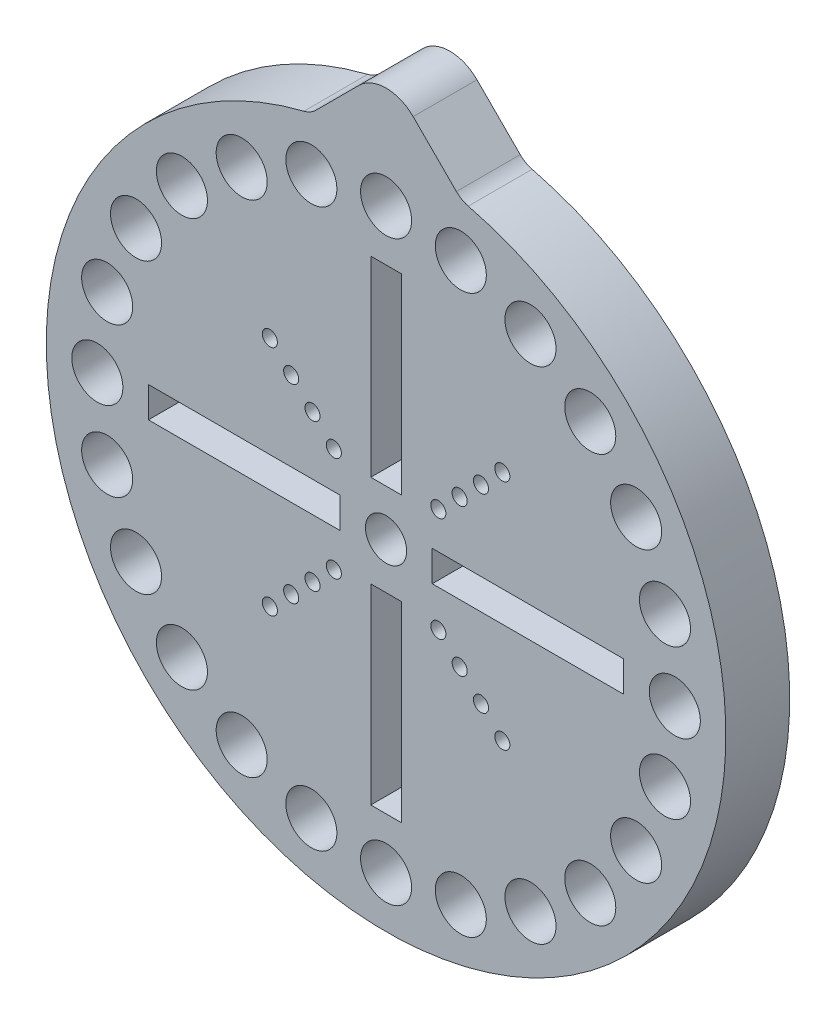
from build123d import *

# Parameters (mm, degrees)
SKETCH1_R           = 33.8
SKETCH1_R_2         = 2.54
SKETCH1_R_3         = 2.05
SKETCH1_R_4         = 0.75
SKETCH1_W           = 3.048
SKETCH1_H           = 19.05
SKETCH1_W_2         = 19.05
SKETCH1_H_2         = 3.048
BOSS_EXTRUDE1_DEPTH = 6.35
BOSS_EXTRUDE2_DEPTH = 6.35
FILLET1_R           = 2.54


with BuildPart() as part:
    # Sketch1 → Boss-Extrude1 (new body)
    with BuildSketch(Plane.XY):
        Circle(SKETCH1_R)
        with Locations((14.36, 24.872249597)):
            Circle(SKETCH1_R_2, mode=Mode.SUBTRACT)
        with Locations((20.308106756, 20.308106756)):
            Circle(SKETCH1_R_2, mode=Mode.SUBTRACT)
        with Locations((24.872249597, 14.36)):
            Circle(SKETCH1_R_2, mode=Mode.SUBTRACT)
        with Locations((27.741389731, 7.433282975)):
            Circle(SKETCH1_R_2, mode=Mode.SUBTRACT)
        with Locations((28.72, 0)):
            Circle(SKETCH1_R_2, mode=Mode.SUBTRACT)
        with Locations((27.741389731, -7.433282975)):
            Circle(SKETCH1_R_2, mode=Mode.SUBTRACT)
        with Locations((24.872249597, -14.36)):
            Circle(SKETCH1_R_2, mode=Mode.SUBTRACT)
        with Locations((20.308106756, -20.308106756)):
            Circle(SKETCH1_R_2, mode=Mode.SUBTRACT)
        with Locations((14.36, -24.872249597)):
            Circle(SKETCH1_R_2, mode=Mode.SUBTRACT)
        with Locations((7.433282975, -27.741389731)):
            Circle(SKETCH1_R_2, mode=Mode.SUBTRACT)
        with Locations((0, -28.72)):
            Circle(SKETCH1_R_2, mode=Mode.SUBTRACT)
        with Locations((-7.433282975, -27.741389731)):
            Circle(SKETCH1_R_2, mode=Mode.SUBTRACT)
        with Locations((-14.36, -24.872249597)):
            Circle(SKETCH1_R_2, mode=Mode.SUBTRACT)
        with Locations((-20.308106756, -20.308106756)):
            Circle(SKETCH1_R_2, mode=Mode.SUBTRACT)
        with Locations((-24.872249597, -14.36)):
            Circle(SKETCH1_R_2, mode=Mode.SUBTRACT)
        with Locations((-27.741389731, -7.433282975)):
            Circle(SKETCH1_R_2, mode=Mode.SUBTRACT)
        with Locations((-28.72, 0)):
            Circle(SKETCH1_R_2, mode=Mode.SUBTRACT)
        with Locations((-27.741389731, 7.433282975)):
            Circle(SKETCH1_R_2, mode=Mode.SUBTRACT)
        with Locations((-24.872249597, 14.36)):
            Circle(SKETCH1_R_2, mode=Mode.SUBTRACT)
        with Locations((-20.308106756, 20.308106756)):
            Circle(SKETCH1_R_2, mode=Mode.SUBTRACT)
        with Locations((-14.36, 24.872249597)):
            Circle(SKETCH1_R_2, mode=Mode.SUBTRACT)
        with Locations((-7.433282975, 27.741389731)):
            Circle(SKETCH1_R_2, mode=Mode.SUBTRACT)
        with Locations((0, 28.72)):
            Circle(SKETCH1_R_2, mode=Mode.SUBTRACT)
        with Locations((7.433282975, 27.741389731)):
            Circle(SKETCH1_R_2, mode=Mode.SUBTRACT)
        Circle(SKETCH1_R_3, mode=Mode.SUBTRACT)
        with Locations((11.561195872, 11.561195872)):
            Circle(SKETCH1_R_4, mode=Mode.SUBTRACT)
        with Locations((9.439875529, 9.439875529)):
            Circle(SKETCH1_R_4, mode=Mode.SUBTRACT)
        with Locations((7.318555185, 7.318555185)):
            Circle(SKETCH1_R_4, mode=Mode.SUBTRACT)
        with Locations((5.197234842, 5.197234842)):
            Circle(SKETCH1_R_4, mode=Mode.SUBTRACT)
        with Locations((11.561195872, -11.561195872)):
            Circle(SKETCH1_R_4, mode=Mode.SUBTRACT)
        with Locations((9.439875529, -9.439875529)):
            Circle(SKETCH1_R_4, mode=Mode.SUBTRACT)
        with Locations((7.318555185, -7.318555185)):
            Circle(SKETCH1_R_4, mode=Mode.SUBTRACT)
        with Locations((5.197234842, -5.197234842)):
            Circle(SKETCH1_R_4, mode=Mode.SUBTRACT)
        with Locations((-11.561195872, -11.561195872)):
            Circle(SKETCH1_R_4, mode=Mode.SUBTRACT)
        with Locations((-9.439875529, -9.439875529)):
            Circle(SKETCH1_R_4, mode=Mode.SUBTRACT)
        with Locations((-7.318555185, -7.318555185)):
            Circle(SKETCH1_R_4, mode=Mode.SUBTRACT)
        with Locations((-5.197234842, -5.197234842)):
            Circle(SKETCH1_R_4, mode=Mode.SUBTRACT)
        with Locations((-11.561195872, 11.561195872)):
            Circle(SKETCH1_R_4, mode=Mode.SUBTRACT)
        with Locations((-9.439875529, 9.439875529)):
            Circle(SKETCH1_R_4, mode=Mode.SUBTRACT)
        with Locations((-7.318555185, 7.318555185)):
            Circle(SKETCH1_R_4, mode=Mode.SUBTRACT)
        with Locations((-5.197234842, 5.197234842)):
            Circle(SKETCH1_R_4, mode=Mode.SUBTRACT)
        with Locations((0, 14.115)):
            Rectangle(SKETCH1_W, SKETCH1_H, mode=Mode.SUBTRACT)
        with Locations((14.115, 0)):
            Rectangle(SKETCH1_W_2, SKETCH1_H_2, mode=Mode.SUBTRACT)
        with Locations((0, -14.115)):
            Rectangle(SKETCH1_W, SKETCH1_H, mode=Mode.SUBTRACT)
        with Locations((-14.115, 0)):
            Rectangle(SKETCH1_W_2, SKETCH1_H_2, mode=Mode.SUBTRACT)
    extrude(amount=BOSS_EXTRUDE1_DEPTH)

    # Sketch3 → Boss-Extrude2 (add)
    with BuildSketch(Plane.XY):
        with BuildLine():
            Line((-2.694076836, 37.764076836), (-7.50097995, 32.957173723))
            ThreePointArc((-7.50097995, 32.957173723), (0, 33.8), (7.50097995, 32.957173723))
            Line((7.50097995, 32.957173723), (2.694076836, 37.764076836))
            ThreePointArc((2.694076836, 37.764076836), (0, 38.88), (-2.694076836, 37.764076836))
        make_face()
    extrude(amount=BOSS_EXTRUDE2_DEPTH)

    # Fillet1
    fillet1_edges = [part.edges().sort_by_distance(p)[0] for p in [
        (-7.50097995, 32.957173723, 3.175),
        (7.50097995, 32.957173723, 3.175),
    ]]
    fillet(fillet1_edges, radius=FILLET1_R)


solid = part.part
